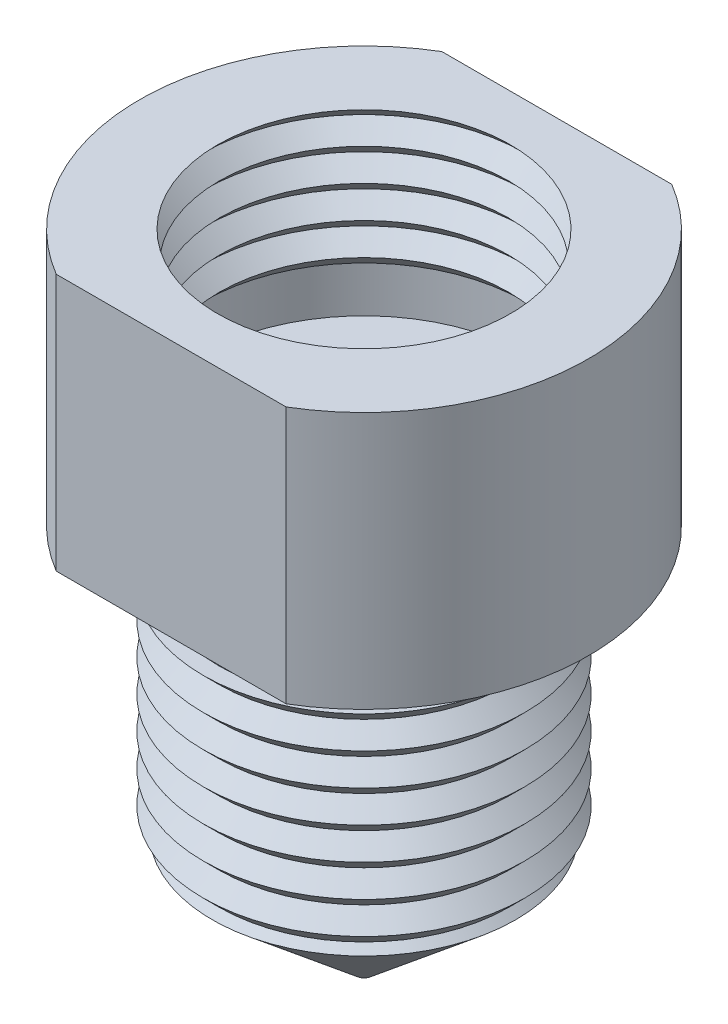
from build123d import *

# Parameters (mm, degrees)
SKETCH2_OUTSIDE_W   = 21.592
SKETCH2_OUTSIDE_H   = 21.592
SKETCH2_OUTSIDE_W_2 = 21.785609725
SKETCH2_OUTSIDE_H_2 = 12
CUT_EXTRUDE1_DEPTH  = 21


with BuildPart() as part:
    # Sketch1 → Revolve1 (revolve)
    with BuildSketch(Plane.XY):
        Polygon((5.1435, -5.969), (1.5875, -5.969), (1.5875, -17.90602957), (0.25, -19.5), (0.25, -20), (4.722297129, -16.247297129), (4.5, -16.025), (5, -15.525), (4.5, -15.025), (5, -14.525), (4.5, -14.025), (5, -13.525), (4.5, -13.025), (5, -12.525), (4.5, -12.025), (5, -11.525), (4.5, -11.025), (5, -10.525), (4.5, -10.025), (5, -9.525), (4.5, -9.525), (4.5, -8.001), (6.985, -8.001), (6.985, 0), (4.555, 0), (5, -0.445), (4.5, -0.945), (5, -1.445), (4.5, -1.945), (5, -2.445), (4.5, -2.945), (5, -3.445), (4.5, -3.945), (5, -4.445), (5.1435, -4.445), align=None)
    revolve(axis=Axis((0, 0, 0), (0, -1, 0)))

    # Sketch2 outside → Cut-Extrude1 (cut, through all)
    with BuildSketch(Plane(origin=(0, 0, 0), x_dir=(1, 0, 0), z_dir=(0, 1, 0))):
        Rectangle(SKETCH2_OUTSIDE_W, SKETCH2_OUTSIDE_H)
        with Locations((0.61693762, 0)):
            Rectangle(SKETCH2_OUTSIDE_W_2, SKETCH2_OUTSIDE_H_2, mode=Mode.SUBTRACT)
    extrude(amount=-CUT_EXTRUDE1_DEPTH, mode=Mode.SUBTRACT)


solid = part.part
